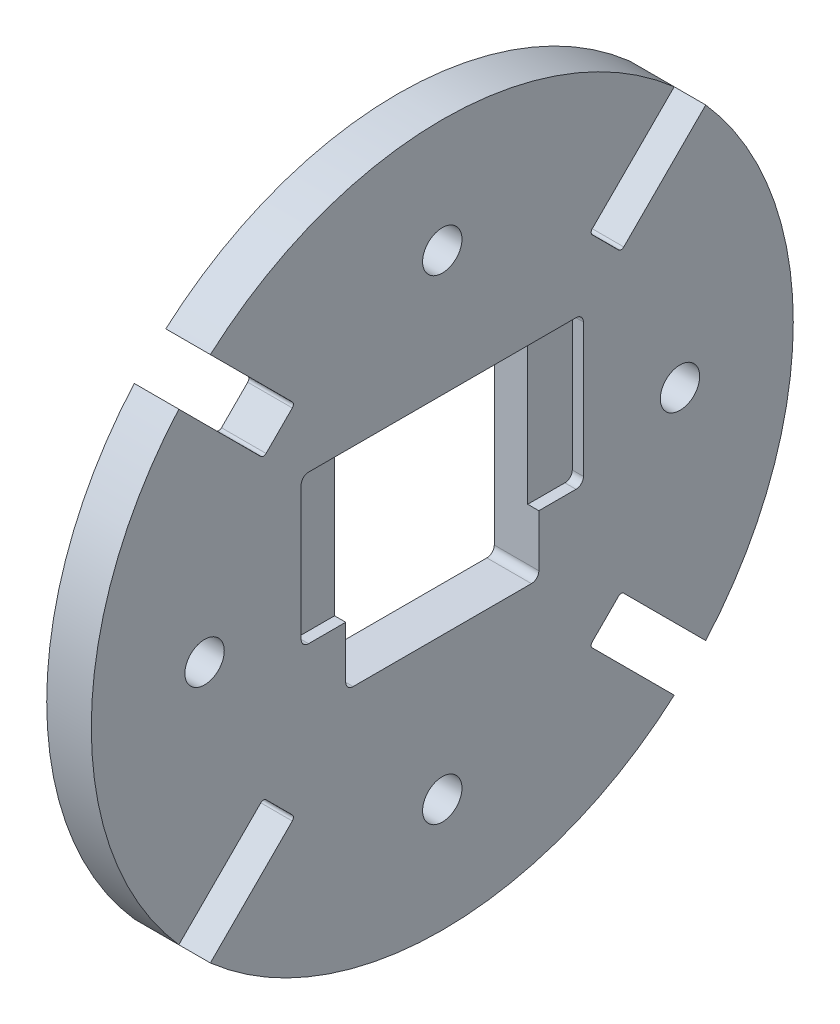
from build123d import *

# Parameters (mm, degrees)
SKETCH1_R                = 47.25
BOSS_EXTRUDE1_DEPTH      = 6
CUT_EXTRUDE1_DEPTH       = 20
M5_CLEARANCE_HOLE1_D     = 5.3
M5_CLEARANCE_HOLE1_DEPTH = 16
M5_CLEARANCE_HOLE1_TIP   = 1.59228064
SKETCH16_W               = 38
SKETCH16_H               = 20
CUT_EXTRUDE2_DEPTH       = 1.5
FILLET1_R                = 1
CUT_EXTRUDE3_START       = -10
CUT_EXTRUDE3_DEPTH       = 10


with BuildPart() as part:
    # Sketch1 → Boss-Extrude1 (new body)
    with BuildSketch(Plane(origin=(0, 0, 0), x_dir=(0, 0, -1), z_dir=(1, 0, 0))):
        Circle(SKETCH1_R)
    extrude(amount=BOSS_EXTRUDE1_DEPTH)

    # Sketch2 → Cut-Extrude1 (cut)
    with BuildSketch(Plane(origin=(6, 0, 0), x_dir=(0, 0, -1), z_dir=(1, 0, 0))):
        with BuildLine():
            Line((-12, -12.85), (12, -12.85))
            ThreePointArc((12, -12.85), (12.707106781, -12.557106781), (13, -11.85))
            Line((13, -11.85), (13, 14.15))
            ThreePointArc((13, 14.15), (12.707106781, 14.857106781), (12, 15.15))
            Line((12, 15.15), (-12, 15.15))
            ThreePointArc((-12, 15.15), (-12.707106781, 14.857106781), (-13, 14.15))
            Line((-13, 14.15), (-13, -11.85))
            ThreePointArc((-13, -11.85), (-12.707106781, -12.557106781), (-12, -12.85))
        make_face()
    extrude(amount=-CUT_EXTRUDE1_DEPTH, mode=Mode.SUBTRACT)

    # M5 Clearance Hole1
    with Locations(Plane.ZY):
        with Locations((-32, 0), (0, 32), (32, 0), (0, -32)):
            Hole(M5_CLEARANCE_HOLE1_D / 2, depth=M5_CLEARANCE_HOLE1_DEPTH)
            with Locations((0, 0, -(M5_CLEARANCE_HOLE1_DEPTH + M5_CLEARANCE_HOLE1_TIP / 2))):  # 118° drill point
                Cone(0, M5_CLEARANCE_HOLE1_D / 2, M5_CLEARANCE_HOLE1_TIP, mode=Mode.SUBTRACT)

    # Sketch16 → Cut-Extrude2 (cut)
    with BuildSketch(Plane(origin=(6, 0, 0), x_dir=(0, 0, -1), z_dir=(1, 0, 0))):
        with Locations((0, 5.15)):
            Rectangle(SKETCH16_W, SKETCH16_H)
    extrude(amount=-CUT_EXTRUDE2_DEPTH, mode=Mode.SUBTRACT)

    # Fillet1
    fillet1_edges = [part.edges().sort_by_distance(p)[0] for p in [
        (5.25, -4.85, -19),
        (5.25, -4.85, 19),
        (5.25, 15.15, 19),
        (5.25, 15.15, -19),
    ]]
    fillet(fillet1_edges, radius=FILLET1_R)

    # Sketch17 → Cut-Extrude3 (cut)
    with BuildSketch(Plane(origin=(6, 0, 0), x_dir=(0, 0, -1), z_dir=(1, 0, 0)).offset(CUT_EXTRUDE3_START)):
        with BuildLine():
            Line((23.723432509, -20.187898603), (20.187898603, -23.723432509))
            ThreePointArc((20.187898603, -23.723432509), (20.041451993, -24.076985899), (20.187898603, -24.43053929))
            Line((20.187898603, -24.43053929), (31.222063558, -35.464704245))
            ThreePointArc((31.222063558, -35.464704245), (33.410795411, -33.410795411), (35.464704245, -31.222063558))
            Line((35.464704245, -31.222063558), (24.43053929, -20.187898603))
            ThreePointArc((24.43053929, -20.187898603), (24.076985899, -20.041451993), (23.723432509, -20.187898603))
        make_face()
        with BuildLine():
            Line((-20.187898603, -23.723432509), (-23.723432509, -20.187898603))
            ThreePointArc((-23.723432509, -20.187898603), (-24.076985899, -20.041451993), (-24.43053929, -20.187898603))
            Line((-24.43053929, -20.187898603), (-35.464704245, -31.222063558))
            ThreePointArc((-35.464704245, -31.222063558), (-33.410795411, -33.410795411), (-31.222063558, -35.464704245))
            Line((-31.222063558, -35.464704245), (-20.187898603, -24.43053929))
            ThreePointArc((-20.187898603, -24.43053929), (-20.041451993, -24.076985899), (-20.187898603, -23.723432509))
        make_face()
        with BuildLine():
            Line((-23.723432509, 20.187898603), (-20.187898603, 23.723432509))
            ThreePointArc((-20.187898603, 23.723432509), (-20.041451993, 24.076985899), (-20.187898603, 24.43053929))
            Line((-20.187898603, 24.43053929), (-31.222063558, 35.464704245))
            ThreePointArc((-31.222063558, 35.464704245), (-33.410795411, 33.410795411), (-35.464704245, 31.222063558))
            Line((-35.464704245, 31.222063558), (-24.43053929, 20.187898603))
            ThreePointArc((-24.43053929, 20.187898603), (-24.076985899, 20.041451993), (-23.723432509, 20.187898603))
        make_face()
        with BuildLine():
            Line((20.187898603, 23.723432509), (23.723432509, 20.187898603))
            ThreePointArc((23.723432509, 20.187898603), (24.076985899, 20.041451993), (24.43053929, 20.187898603))
            Line((24.43053929, 20.187898603), (35.464704245, 31.222063558))
            ThreePointArc((35.464704245, 31.222063558), (33.410795411, 33.410795411), (31.222063558, 35.464704245))
            Line((31.222063558, 35.464704245), (20.187898603, 24.43053929))
            ThreePointArc((20.187898603, 24.43053929), (20.041451993, 24.076985899), (20.187898603, 23.723432509))
        make_face()
    extrude(amount=CUT_EXTRUDE3_DEPTH, mode=Mode.SUBTRACT)


solid = part.part
